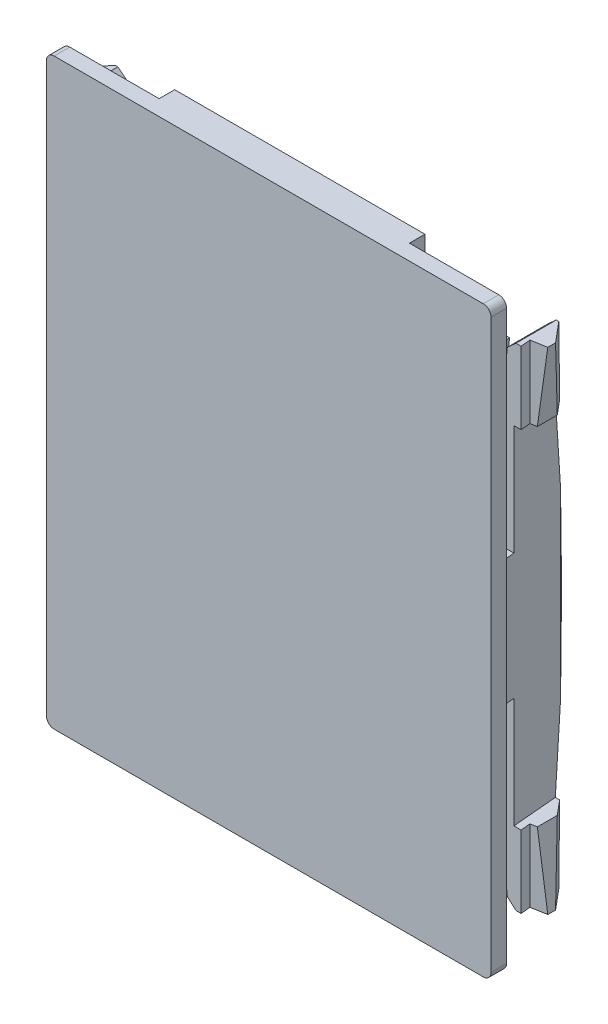
from build123d import *

# Parameters (mm, degrees)
BOSS_EXTRUDE1_DEPTH      = 2
BOSS_EXTRUDE2_DEPTH      = 1.7
BOSS_EXTRUDE2_DEPTH_BACK = 1.7
BOSS_EXTRUDE3_DEPTH      = 1.7
BOSS_EXTRUDE3_DEPTH_BACK = 1.7
BOSS_EXTRUDE4_DEPTH      = 1.7
BOSS_EXTRUDE4_DEPTH_BACK = 1.7
BOSS_EXTRUDE5_DEPTH      = 1.7
BOSS_EXTRUDE5_DEPTH_BACK = 1.7
SKETCH6_W                = 38.6
SKETCH6_H                = 47.5
CUT_EXTRUDE1_DEPTH       = 4
BOSS_EXTRUDE6_DEPTH      = 3.8
BOSS_EXTRUDE7_DEPTH      = 3.8
CUT_EXTRUDE2_DEPTH       = 20
CUT_EXTRUDE2_DEPTH_BACK  = 20
CUT_EXTRUDE3_DEPTH       = 11.15
CUT_EXTRUDE3_DEPTH_BACK  = 11.15
CUT_EXTRUDE4_DEPTH       = 11.15
CUT_EXTRUDE4_DEPTH_BACK  = 11.15
CUT_EXTRUDE5_DEPTH       = 16
CUT_EXTRUDE5_DEPTH_BACK  = 16
CUT_EXTRUDE6_DEPTH       = 16
CUT_EXTRUDE6_DEPTH_BACK  = 16


with BuildPart() as part:
    # Sketch1 → Boss-Extrude1 (new body)
    with BuildSketch(Plane.XY):
        with BuildLine():
            Line((-14.3, 18.25), (-14.3, -18.25))
            ThreePointArc((-14.3, -18.25), (-14.153553391, -18.603553391), (-13.8, -18.75))
            Line((-13.8, -18.75), (13.8, -18.75))
            ThreePointArc((13.8, -18.75), (14.153553391, -18.603553391), (14.3, -18.25))
            Line((14.3, -18.25), (14.3, 18.25))
            ThreePointArc((14.3, 18.25), (14.153553391, 18.603553391), (13.8, 18.75))
            Line((13.8, 18.75), (-13.8, 18.75))
            ThreePointArc((-13.8, 18.75), (-14.153553391, 18.603553391), (-14.3, 18.25))
        make_face()
    extrude(amount=BOSS_EXTRUDE1_DEPTH)

    # Sketch2 → Boss-Extrude2 (add, two sides: drawn at the far end of the back side and taken through both)
    with BuildSketch(Plane.XY.offset(-BOSS_EXTRUDE2_DEPTH_BACK)):
        with BuildLine():
            Line((-13.1, 12.5), (-10.1, 12.5))
            ThreePointArc((-10.1, 12.5), (-9.35, 13.25), (-10.1, 14))
            Line((-10.1, 14), (-13.1, 14))
            Line((-13.1, 14), (-13.1, 12.5))
        make_face()
    extrude(amount=BOSS_EXTRUDE2_DEPTH + BOSS_EXTRUDE2_DEPTH_BACK)

    # Sketch3 → Boss-Extrude3 (add, two sides: drawn at the far end of the back side and taken through both)
    with BuildSketch(Plane.XY.offset(-BOSS_EXTRUDE3_DEPTH_BACK)):
        with BuildLine():
            Line((10.1, -14), (13.1, -14))
            Line((13.1, -14), (13.1, -12.5))
            Line((13.1, -12.5), (10.1, -12.5))
            ThreePointArc((10.1, -12.5), (9.35, -13.25), (10.1, -14))
        make_face()
    extrude(amount=BOSS_EXTRUDE3_DEPTH + BOSS_EXTRUDE3_DEPTH_BACK)

    # Sketch4 → Boss-Extrude4 (add, two sides: drawn at the far end of the back side and taken through both)
    with BuildSketch(Plane.XY.offset(-BOSS_EXTRUDE4_DEPTH_BACK)):
        with BuildLine():
            Line((-13.1, -12.5), (-13.1, -14))
            Line((-13.1, -14), (-10.1, -14))
            ThreePointArc((-10.1, -14), (-9.35, -13.25), (-10.1, -12.5))
            Line((-10.1, -12.5), (-13.1, -12.5))
        make_face()
    extrude(amount=BOSS_EXTRUDE4_DEPTH + BOSS_EXTRUDE4_DEPTH_BACK)

    # Sketch5 → Boss-Extrude5 (add, two sides: drawn at the far end of the back side and taken through both)
    with BuildSketch(Plane.XY.offset(-BOSS_EXTRUDE5_DEPTH_BACK)):
        with BuildLine():
            Line((10.1, 12.5), (13.1, 12.5))
            Line((13.1, 12.5), (13.1, 14))
            Line((13.1, 14), (10.1, 14))
            ThreePointArc((10.1, 14), (9.35, 13.25), (10.1, 12.5))
        make_face()
    extrude(amount=BOSS_EXTRUDE5_DEPTH + BOSS_EXTRUDE5_DEPTH_BACK)

    # Sketch6 → Cut-Extrude1 (cut)
    with BuildSketch(Plane.XY.offset(-3)):
        Rectangle(SKETCH6_W, SKETCH6_H)
        with BuildLine():
            Line((-14.3, -4.045), (-11.298993595, -4.045))
            ThreePointArc((-11.298993595, -4.045), (-10.927421183, -4.210434697), (-10.801732648, -4.597264232))
            Line((-10.801732648, -4.597264232), (-11.79, -14))
            Line((-11.79, -14), (-8.55, -14))
            ThreePointArc((-8.55, -14), (-8.196446609, -14.146446609), (-8.05, -14.5))
            Line((-8.05, -14.5), (-8.05, -18.75))
            Line((-8.05, -18.75), (8.05, -18.75))
            Line((8.05, -18.75), (8.05, -14.5))
            ThreePointArc((8.05, -14.5), (8.196446609, -14.146446609), (8.55, -14))
            Line((8.55, -14), (11.79, -14))
            Line((11.79, -14), (10.801732648, -4.597264232))
            ThreePointArc((10.801732648, -4.597264232), (10.927421183, -4.210434697), (11.298993595, -4.045))
            Line((11.298993595, -4.045), (14.3, -4.045))
            Line((14.3, -4.045), (14.3, 4.045))
            Line((14.3, 4.045), (11.298993595, 4.045))
            ThreePointArc((11.298993595, 4.045), (10.927421183, 4.210434697), (10.801732648, 4.597264232))
            Line((10.801732648, 4.597264232), (11.79, 14))
            Line((11.79, 14), (8.55, 14))
            ThreePointArc((8.55, 14), (8.196446609, 14.146446609), (8.05, 14.5))
            Line((8.05, 14.5), (8.05, 18.75))
            Line((8.05, 18.75), (-8.05, 18.75))
            Line((-8.05, 18.75), (-8.05, 14.5))
            ThreePointArc((-8.05, 14.5), (-8.196446609, 14.146446609), (-8.55, 14))
            Line((-8.55, 14), (-11.79, 14))
            Line((-11.79, 14), (-10.801732648, 4.597264232))
            ThreePointArc((-10.801732648, 4.597264232), (-10.927421183, 4.210434697), (-11.298993595, 4.045))
            Line((-11.298993595, 4.045), (-14.3, 4.045))
            Line((-14.3, 4.045), (-14.3, -4.045))
        make_face(mode=Mode.SUBTRACT)
    extrude(amount=CUT_EXTRUDE1_DEPTH, mode=Mode.SUBTRACT)

    # Sketch7 → Boss-Extrude6 (add)
    with BuildSketch(Plane.XY.offset(-3.6)):
        Polygon((12.36, -4.002188077), (13.547735768, -15.302739052), (14.1, -15.8), (15.35, -15.8), (14.779051792, -11.15), (14.04, -11.15), (14.04, 11.15), (14.779051792, 11.15), (15.35, 15.8), (14.1, 15.8), (13.547735768, 15.302739052), (12.36, 4.002188077), align=None)
    extrude(amount=BOSS_EXTRUDE6_DEPTH)

    # Sketch8 → Boss-Extrude7 (add)
    with BuildSketch(Plane.XY.offset(-3.6)):
        Polygon((-15.35, -15.8), (-14.1, -15.8), (-13.547735768, -15.302739052), (-12.36, -4.002188077), (-12.36, 4.002188077), (-13.547735768, 15.302739052), (-14.1, 15.8), (-15.35, 15.8), (-14.779051792, 11.15), (-14.04, 11.15), (-14.04, -11.15), (-14.779051792, -11.15), align=None)
    extrude(amount=BOSS_EXTRUDE7_DEPTH)

    # Sketch9 → Cut-Extrude2 (cut, two sides: drawn at the far end of the back side and taken through both)
    with BuildSketch(Plane(origin=(0, 0, 0), x_dir=(0, 0, -1), z_dir=(1, 0, 0)).offset(-CUT_EXTRUDE2_DEPTH_BACK)):
        Polygon((2.395156371, -15.8), (8.5, -15.8), (8.5, 15.8), (2.395156371, 15.8), (3.5, 0), align=None)
    extrude(amount=CUT_EXTRUDE2_DEPTH + CUT_EXTRUDE2_DEPTH_BACK, mode=Mode.SUBTRACT)

    # Sketch10 → Cut-Extrude3 (cut, two sides: drawn at the far end of the back side and taken through both)
    with BuildSketch(Plane(origin=(0, 0, 0), x_dir=(1, 0, 0), z_dir=(0, 1, 0)).offset(-CUT_EXTRUDE3_DEPTH_BACK)):
        Polygon((13.602556682, 4), (14.04, -1), (14.3, -1), (14.3, 4), align=None)
    extrude(amount=CUT_EXTRUDE3_DEPTH + CUT_EXTRUDE3_DEPTH_BACK, mode=Mode.SUBTRACT)

    # Sketch11 → Cut-Extrude4 (cut, two sides: drawn at the far end of the back side and taken through both)
    with BuildSketch(Plane(origin=(0, 0, 0), x_dir=(1, 0, 0), z_dir=(0, 1, 0)).offset(-CUT_EXTRUDE4_DEPTH_BACK)):
        Polygon((-14.3, 4), (-14.3, -1), (-14.04, -1), (-13.602556682, 4), align=None)
    extrude(amount=CUT_EXTRUDE4_DEPTH + CUT_EXTRUDE4_DEPTH_BACK, mode=Mode.SUBTRACT)

    # Sketch12 → Cut-Extrude5 (cut, two sides: drawn at the far end of the back side and taken through both)
    with BuildSketch(Plane(origin=(0, 0, 0), x_dir=(1, 0, 0), z_dir=(0, 1, 0)).offset(-CUT_EXTRUDE5_DEPTH_BACK)):
        Polygon((12.35, 4.8), (12.35, 4.675260778), (15.35, 1.1), (15.35, 0.6), (14.375049256, 0.428089879), (14.43, -0.2), (17.35, -0.2), (17.35, 4.8), align=None)
    extrude(amount=CUT_EXTRUDE5_DEPTH + CUT_EXTRUDE5_DEPTH_BACK, mode=Mode.SUBTRACT)

    # Sketch13 → Cut-Extrude6 (cut, two sides: drawn at the far end of the back side and taken through both)
    with BuildSketch(Plane(origin=(0, 0, 0), x_dir=(1, 0, 0), z_dir=(0, 1, 0)).offset(-CUT_EXTRUDE6_DEPTH_BACK)):
        Polygon((-17.35, 4.8), (-17.35, -0.2), (-14.43, -0.2), (-14.375049256, 0.428089879), (-15.35, 0.6), (-15.35, 1.1), (-12.35, 4.675260778), (-12.35, 4.8), align=None)
    extrude(amount=CUT_EXTRUDE6_DEPTH + CUT_EXTRUDE6_DEPTH_BACK, mode=Mode.SUBTRACT)


solid = part.part
